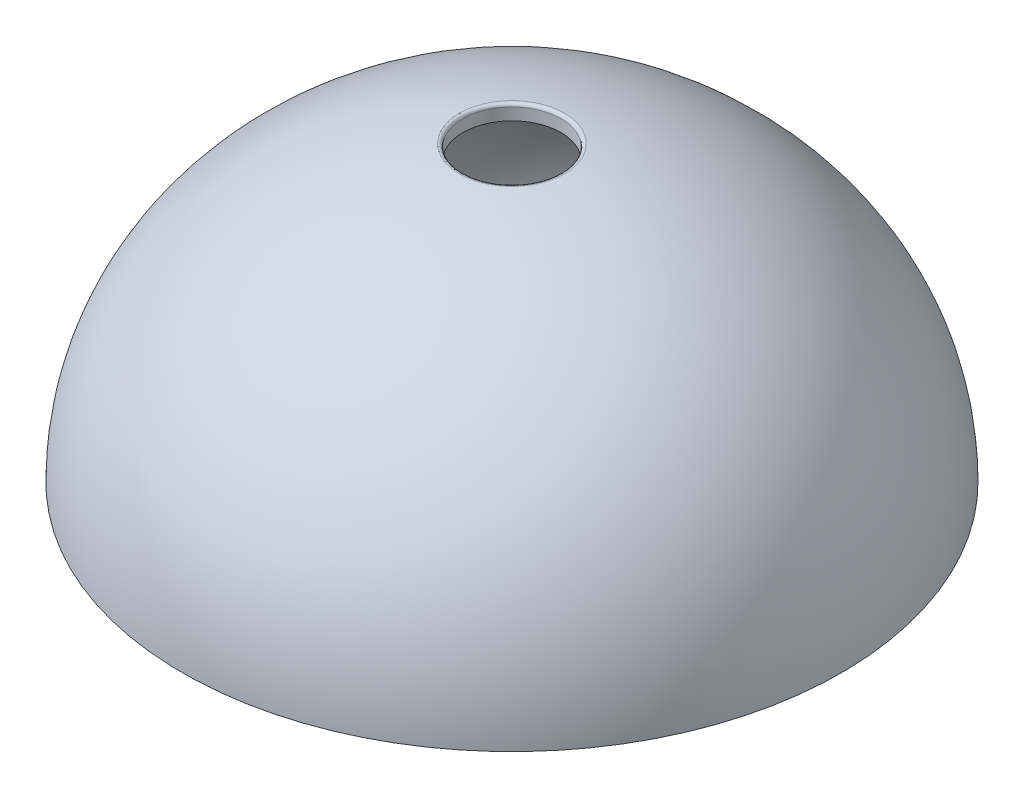
from build123d import *

# Parameters (mm, degrees)
BELL_SHELL_T   = -0.5
HOLE_CIRCLE_R  = 1.6
HOLE_CUT_DEPTH = 10.7000001
HOLE_FILLET_R  = 0.1


with BuildPart() as part:
    # Bell Ellipse Profile → Bell Hemisphere (revolve)
    with BuildSketch(Plane.XY):
        with BuildLine():
            Line((10.75, 0), (0, 0))
            Line((0, 0), (0, 9.7))
            add(Edge.make_bspline(
                [(10.75, 0), (10.75, 9.7), (0, 9.7)],
                knots=[0, 0, 0, 1.570796327, 1.570796327, 1.570796327], degree=2, weights=[1, 0.707106781, 1]))
        make_face()
    revolve(axis=Axis((0, -20.561940231, 0), (0, 1, 0)))

    # Bell Shell
    bell_shell_openings = [part.faces().sort_by_distance(p)[0] for p in [
        (0, 0, -10.75),
    ]]
    offset(amount=BELL_SHELL_T, openings=bell_shell_openings, kind=Kind.INTERSECTION)

    # Hole Circle → Hole Cut (cut, through all)
    with BuildSketch(Plane(origin=(0, 9.7, 0), x_dir=(-1, 0, 0), z_dir=(0, -1, 0))):
        Circle(HOLE_CIRCLE_R)
    extrude(amount=HOLE_CUT_DEPTH, mode=Mode.SUBTRACT)

    # Hole Fillet
    hole_fillet_edges = [part.edges().sort_by_distance(p)[0] for p in [
        (-1e-09, 9.591958605, -1.6),
    ]]
    fillet(hole_fillet_edges, radius=HOLE_FILLET_R)


solid = part.part
